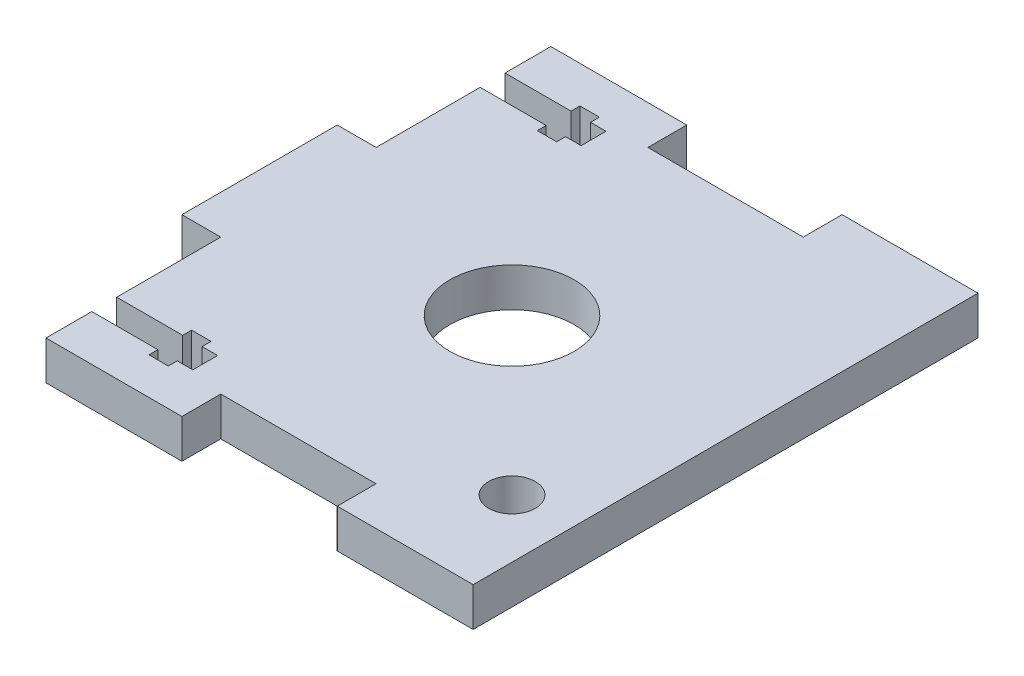
from build123d import *

# Parameters (mm, degrees)
BOSS_EXTRU_1_DEPTH      = 5
ESQUISSE2_R             = 8
ENL_V_MAT_EXTRU_1_DEPTH = 10
ENL_V_MAT_EXTRU_2_DEPTH = 10
ESQUISSE4_R             = 3
ENL_V_MAT_EXTRU_3_DEPTH = 10


with BuildPart() as part:
    # Esquisse1 → Boss.-Extru.1 (new body)
    with BuildSketch(Plane(origin=(0, 0, 0), x_dir=(1, 0, 0), z_dir=(0, 1, 0))):
        Polygon((17.5, -5), (37.5, -5), (37.5, 0), (55, 0), (55, -60), (55, -65), (37.5, -65), (37.5, -60), (17.5, -60), (17.5, -65), (0, -65), (0, -60), (0, -42.5), (-5, -42.5), (-5, -22.5), (0, -22.5), (0, 0), (17.5, 0), align=None)
    extrude(amount=BOSS_EXTRU_1_DEPTH)

    # Esquisse2 → Enlèv. mat.-Extru.1 (cut)
    with BuildSketch(Plane(origin=(0, 5, 0), x_dir=(1, 0, 0), z_dir=(0, 1, 0))):
        with Locations((27.5, -32.5)):
            Circle(ESQUISSE2_R)
    extrude(amount=-ENL_V_MAT_EXTRU_1_DEPTH, mode=Mode.SUBTRACT)

    # Esquisse3 → Enlèv. mat.-Extru.2 (cut)
    with BuildSketch(Plane(origin=(0, 5, 0), x_dir=(1, 0, 0), z_dir=(0, 1, 0))):
        Polygon((13, -5.9), (11, -5.9), (11, -4.75), (8.5, -4.75), (8.5, -5.9), (0, -5.9), (0, -9.1), (8.5, -9.1), (8.5, -10.25), (11, -10.25), (11, -9.1), (13, -9.1), align=None)
    enl_v_mat_extru_2 = extrude(amount=-ENL_V_MAT_EXTRU_2_DEPTH, mode=Mode.SUBTRACT)

    # Symétrie1: Enlèv. mat.-Extru.2 across plane
    add(enl_v_mat_extru_2.mirror(Plane(origin=(0, 0, 32.5), x_dir=(1, 0, 0), z_dir=(0, 0, -1))), mode=Mode.SUBTRACT)

    # Esquisse4 → Enlèv. mat.-Extru.3 (cut)
    with BuildSketch(Plane(origin=(0, 5, 0), x_dir=(1, 0, 0), z_dir=(0, 1, 0))):
        with Locations((47.5, -52.5)):
            Circle(ESQUISSE4_R)
    extrude(amount=-ENL_V_MAT_EXTRU_3_DEPTH, mode=Mode.SUBTRACT)


solid = part.part
